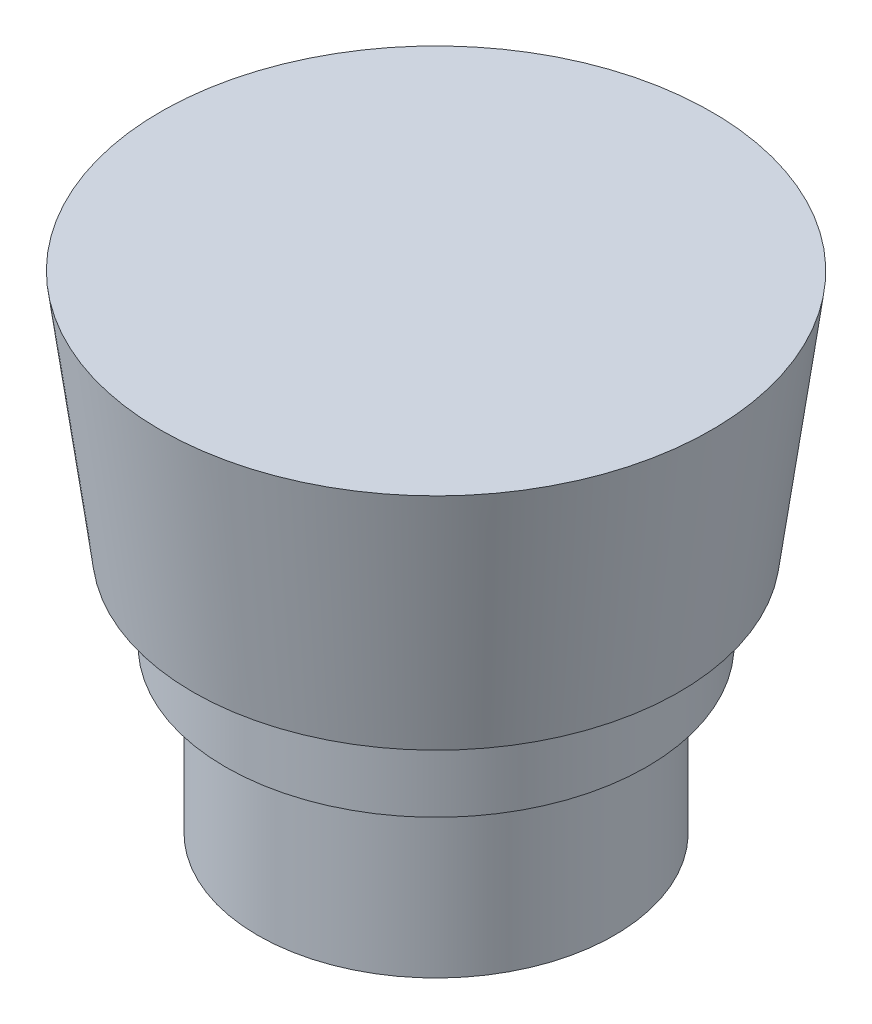
from build123d import *


with BuildPart() as part:
    # Esquisse1 → Révolution1 (revolve)
    with BuildSketch(Plane.XY):
        Polygon((0, -30.535272727), (11, -30.535272727), (11, -20.535272727), (13, -20.535272727), (13, -15.535272727), (15, -15.535272727), (17, -0.535272727), (0, -0.535272727), align=None)
    revolve(axis=Axis((0, 48.227012987, 0), (0, -1, 0)))


solid = part.part
